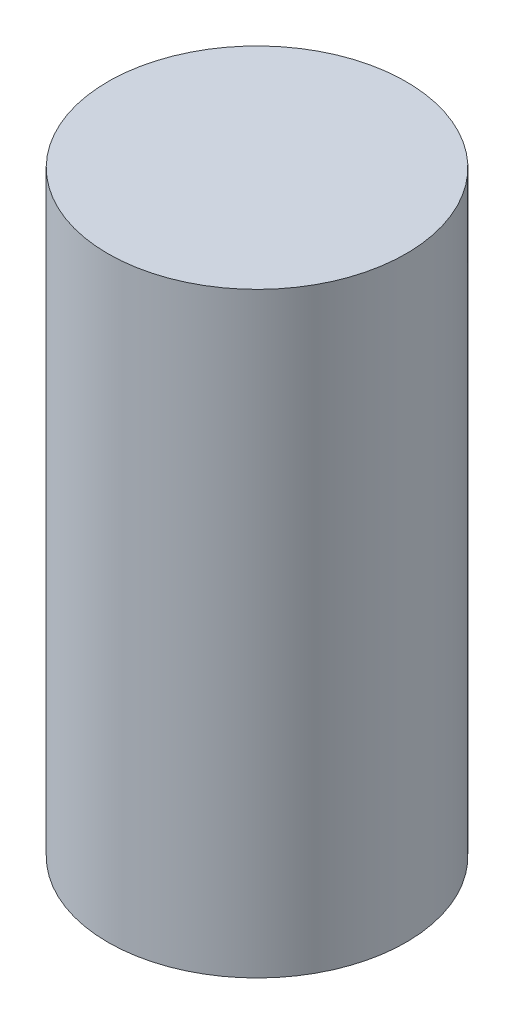
from build123d import *

# Parameters (mm, degrees)
SKETCH1_R           = 5
BOSS_EXTRUDE1_DEPTH = 10


with BuildPart() as part:
    # Sketch1 → Boss-Extrude1 (new body, symmetric)
    with BuildSketch(Plane(origin=(0, 0, 0), x_dir=(1, 0, 0), z_dir=(0, 1, 0))):
        Circle(SKETCH1_R)
    extrude(amount=BOSS_EXTRUDE1_DEPTH, both=True)


solid = part.part
